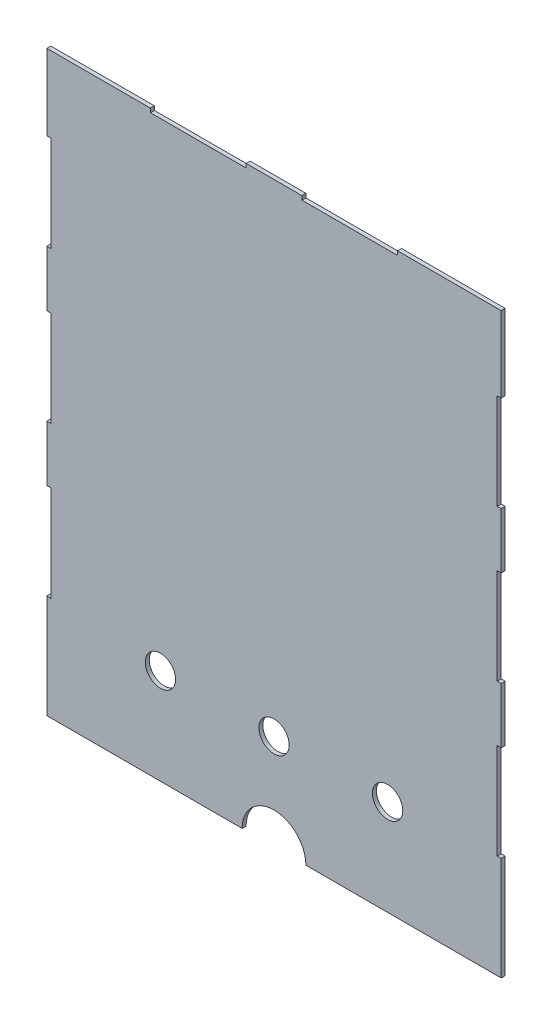
from build123d import *

# Parameters (mm, degrees)
SKETCH1_W           = 361.95
SKETCH1_H           = 460.375
BOSS_EXTRUDE1_DEPTH = 3.175
SKETCH2_W           = 76.2
SKETCH2_H           = 3.175
SKETCH2_W_2         = 3.175
SKETCH2_H_2         = 76.2
CUT_EXTRUDE1_DEPTH  = 3.175
SKETCH3_R           = 12.0777
CUT_EXTRUDE2_DEPTH  = 3.175


with BuildPart() as part:
    # Sketch1 → Boss-Extrude1 (new body)
    with BuildSketch(Plane.XY):
        with Locations((0, 230.1875)):
            Rectangle(SKETCH1_W, SKETCH1_H)
    extrude(amount=BOSS_EXTRUDE1_DEPTH)

    # Sketch2 → Cut-Extrude1 (cut)
    with BuildSketch(Plane.XY.offset(3.175)):
        with Locations((-60.325, 458.7875)):
            Rectangle(SKETCH2_W, SKETCH2_H)
        with Locations((179.3875, 361.95)):
            Rectangle(SKETCH2_W_2, SKETCH2_H_2)
        with Locations((-179.3875, 120.65)):
            Rectangle(SKETCH2_W_2, SKETCH2_H_2)
        with Locations((-179.3875, 241.3)):
            Rectangle(SKETCH2_W_2, SKETCH2_H_2)
        with Locations((-179.3875, 361.95)):
            Rectangle(SKETCH2_W_2, SKETCH2_H_2)
        with Locations((179.3875, 241.3)):
            Rectangle(SKETCH2_W_2, SKETCH2_H_2)
        with Locations((179.3875, 120.65)):
            Rectangle(SKETCH2_W_2, SKETCH2_H_2)
        with Locations((60.325, 458.7875)):
            Rectangle(SKETCH2_W, SKETCH2_H)
    extrude(amount=-CUT_EXTRUDE1_DEPTH, mode=Mode.SUBTRACT)

    # Sketch3 → Cut-Extrude2 (cut)
    with BuildSketch(Plane.XY.offset(3.175)):
        with Locations((-90.4875, 76.2)):
            Circle(SKETCH3_R)
        with Locations((0, 76.2)):
            Circle(SKETCH3_R)
        with Locations((90.4875, 76.2)):
            Circle(SKETCH3_R)
        with BuildLine():
            Line((-25.4, 0), (25.4, 0))
            ThreePointArc((25.4, 0), (0, 25.4), (-25.4, 0))
        make_face()
    extrude(amount=-CUT_EXTRUDE2_DEPTH, mode=Mode.SUBTRACT)


solid = part.part
